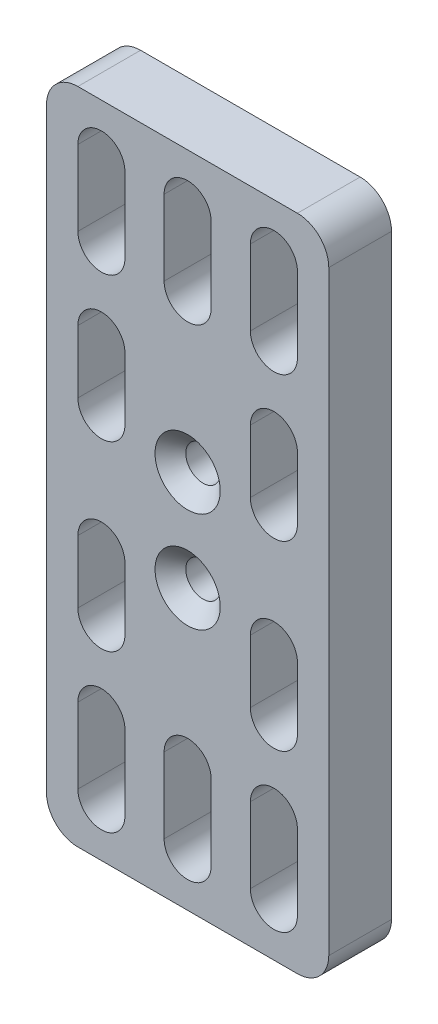
from build123d import *

# Parameters (mm, degrees)
SKETCH1_W                                     = 45
SKETCH1_H                                     = 105
BOSS_EXTRUDE1_DEPTH                           = 10
FILLET1_R                                     = 5
CUT_EXTRUDE1_DEPTH                            = 10
CSK_FOR_M5_COUNTERSUNK_FLAT_HEAD1_D           = 5.5
CSK_FOR_M5_COUNTERSUNK_FLAT_HEAD1_DEPTH       = 30
CSK_FOR_M5_COUNTERSUNK_FLAT_HEAD1_CSINK_D     = 10.4
CSK_FOR_M5_COUNTERSUNK_FLAT_HEAD1_CSINK_ANGLE = 90
CSK_FOR_M5_COUNTERSUNK_FLAT_HEAD1_TIP         = 1.652366702


with BuildPart() as part:
    # Sketch1 → Boss-Extrude1 (new body)
    with BuildSketch(Plane.XY):
        with Locations((22.5, 52.5)):
            Rectangle(SKETCH1_W, SKETCH1_H)
    extrude(amount=BOSS_EXTRUDE1_DEPTH)

    # Fillet1
    fillet1_edges = [part.edges().sort_by_distance(p)[0] for p in [
        (0, 105, 5),
        (45, 105, 5),
        (45, 0, 5),
        (0, 0, 5),
    ]]
    fillet(fillet1_edges, radius=FILLET1_R)

    # Sketch2 → Cut-Extrude1 (cut)
    with BuildSketch(Plane.XY.offset(10)):
        with BuildLine():
            Line((12.5, 20), (12.5, 8))
            ThreePointArc((12.5, 8), (8.75, 4.25), (5, 8))
            Line((5, 8), (5, 20))
            ThreePointArc((5, 20), (8.75, 23.75), (12.5, 20))
        make_face()
        with BuildLine():
            Line((12.5, 72), (12.5, 62))
            ThreePointArc((12.5, 62), (8.75, 58.25), (5, 62))
            Line((5, 62), (5, 72))
            ThreePointArc((5, 72), (8.75, 75.75), (12.5, 72))
        make_face()
        with BuildLine():
            Line((32.5, 20), (32.5, 8))
            ThreePointArc((32.5, 8), (36.25, 4.25), (40, 8))
            Line((40, 8), (40, 20))
            ThreePointArc((40, 20), (36.25, 23.75), (32.5, 20))
        make_face()
        with BuildLine():
            Line((32.5, 72), (32.5, 62))
            ThreePointArc((32.5, 62), (36.25, 58.25), (40, 62))
            Line((40, 62), (40, 72))
            ThreePointArc((40, 72), (36.25, 75.75), (32.5, 72))
        make_face()
        with BuildLine():
            Line((32.5, 85), (32.5, 97))
            ThreePointArc((32.5, 97), (36.25, 100.75), (40, 97))
            Line((40, 97), (40, 85))
            ThreePointArc((40, 85), (36.25, 81.25), (32.5, 85))
        make_face()
        with BuildLine():
            Line((32.5, 33), (32.5, 43))
            ThreePointArc((32.5, 43), (36.25, 46.75), (40, 43))
            Line((40, 43), (40, 33))
            ThreePointArc((40, 33), (36.25, 29.25), (32.5, 33))
        make_face()
        with BuildLine():
            Line((12.5, 85), (12.5, 97))
            ThreePointArc((12.5, 97), (8.75, 100.75), (5, 97))
            Line((5, 97), (5, 85))
            ThreePointArc((5, 85), (8.75, 81.25), (12.5, 85))
        make_face()
        with BuildLine():
            Line((26.25, 85), (26.25, 97))
            ThreePointArc((26.25, 97), (22.5, 100.75), (18.75, 97))
            Line((18.75, 97), (18.75, 85))
            ThreePointArc((18.75, 85), (22.5, 81.25), (26.25, 85))
        make_face()
        with BuildLine():
            Line((26.25, 20), (26.25, 8))
            ThreePointArc((26.25, 8), (22.5, 4.25), (18.75, 8))
            Line((18.75, 8), (18.75, 20))
            ThreePointArc((18.75, 20), (22.5, 23.75), (26.25, 20))
        make_face()
        with BuildLine():
            Line((12.5, 33), (12.5, 43))
            ThreePointArc((12.5, 43), (8.75, 46.75), (5, 43))
            Line((5, 43), (5, 33))
            ThreePointArc((5, 33), (8.75, 29.25), (12.5, 33))
        make_face()
    extrude(amount=-CUT_EXTRUDE1_DEPTH, mode=Mode.SUBTRACT)

    # CSK for M5 Countersunk Flat Head1
    with Locations(Plane.XY.offset(10)):
        with Locations((22.5, 60.5), (22.5, 44.5)):
            CounterSinkHole(CSK_FOR_M5_COUNTERSUNK_FLAT_HEAD1_D / 2, CSK_FOR_M5_COUNTERSUNK_FLAT_HEAD1_CSINK_D / 2, depth=CSK_FOR_M5_COUNTERSUNK_FLAT_HEAD1_DEPTH, counter_sink_angle=CSK_FOR_M5_COUNTERSUNK_FLAT_HEAD1_CSINK_ANGLE)
            with Locations((0, 0, -(CSK_FOR_M5_COUNTERSUNK_FLAT_HEAD1_DEPTH + CSK_FOR_M5_COUNTERSUNK_FLAT_HEAD1_TIP / 2))):  # 118° drill point
                Cone(0, CSK_FOR_M5_COUNTERSUNK_FLAT_HEAD1_D / 2, CSK_FOR_M5_COUNTERSUNK_FLAT_HEAD1_TIP, mode=Mode.SUBTRACT)


solid = part.part
